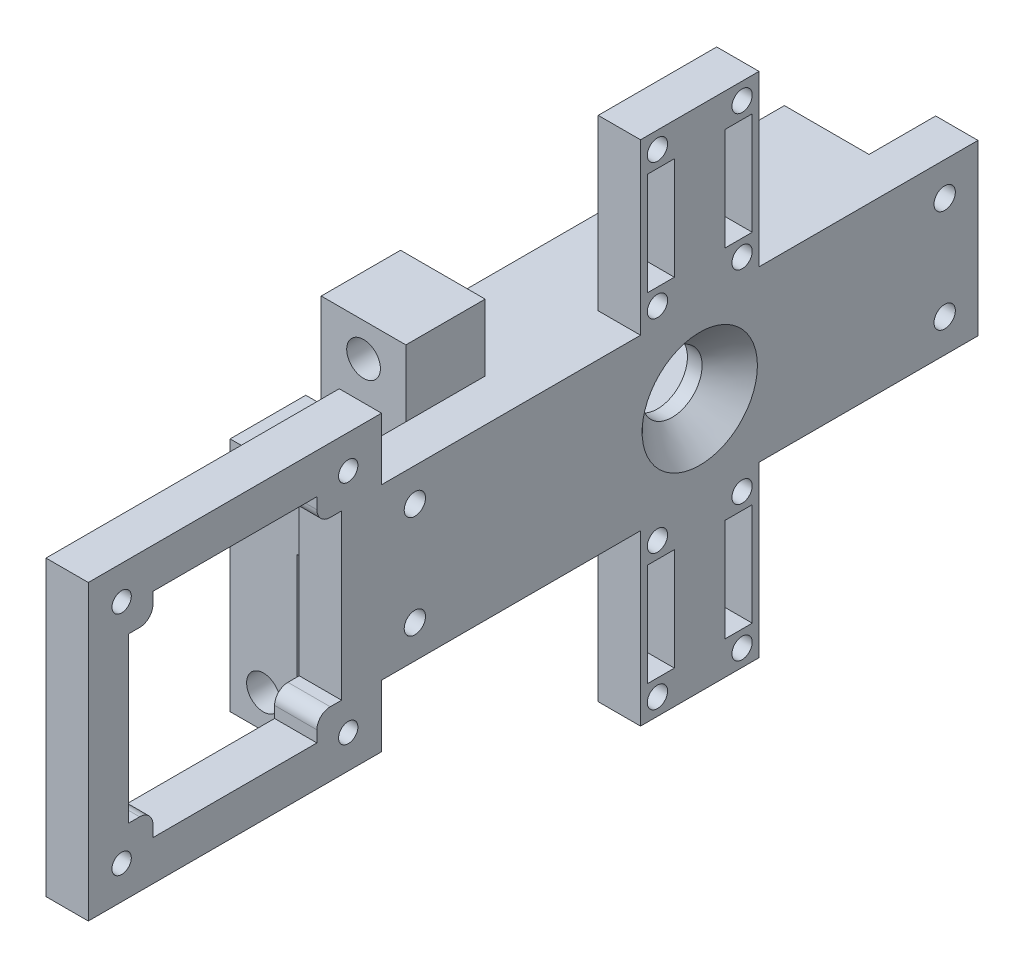
from build123d import *
from build123d.topology import SkipClean

# Parameters (mm, degrees)
SKETCH1_W                                       = 6.35
SKETCH1_H                                       = 89.5
BOSS_EXTRUDE1_DEPTH                             = 25.4
SKETCH4_W                                       = 44
SKETCH4_H                                       = 44
SKETCH4_R                                       = 1.45
BOSS_EXTRUDE2_DEPTH                             = 6.35
CSK_FOR_M8_FLAT_HEAD_MACHINE_SCREW1_D           = 9
CSK_FOR_M8_FLAT_HEAD_MACHINE_SCREW1_DEPTH       = 17.5
CSK_FOR_M8_FLAT_HEAD_MACHINE_SCREW1_CSINK_D     = 17.3
CSK_FOR_M8_FLAT_HEAD_MACHINE_SCREW1_CSINK_ANGLE = 90
CSK_FOR_M8_FLAT_HEAD_MACHINE_SCREW1_TIP         = 2.703872786
SKETCH2_W                                       = 69.5
SKETCH2_H                                       = 25.4
SKETCH2_W_2                                     = 52.8
SKETCH2_H_2                                     = 14.7
BOSS_EXTRUDE3_DEPTH                             = 12.7
SKETCH9_R                                       = 1.6
CUT_EXTRUDE1_DEPTH                              = 6.35
SKETCH10_W                                      = 17.78
SKETCH10_H                                      = 25.4
SKETCH10_R                                      = 1.524
BOSS_EXTRUDE4_DEPTH                             = 6.35
SKETCH11_W                                      = 4.064
SKETCH11_H                                      = 15.4
CUT_EXTRUDE2_DEPTH                              = 6.35
SKETCH14_W                                      = 12.7
SKETCH14_H                                      = 11.9
BOSS_EXTRUDE5_DEPTH                             = 10
SKETCH15_R                                      = 2.5273
CUT_EXTRUDE4_DEPTH                              = 7
SKETCH16_W                                      = 11.35
SKETCH16_H                                      = 10
BOSS_EXTRUDE6_DEPTH                             = 13.671834
SKETCH17_W                                      = 10
SKETCH17_H                                      = 11.35
BOSS_EXTRUDE7_DEPTH                             = 25.452256
SKETCH18_R                                      = 2.5273
CUT_EXTRUDE5_DEPTH                              = 7
SKETCH19_W                                      = 5.3384296
SKETCH19_H                                      = 10
BOSS_EXTRUDE8_DEPTH                             = 5.35
SKETCH21_W                                      = 14.8000118
SKETCH21_H                                      = 5
SKETCH21_W_2                                    = 14.5200118
SKETCH21_H_2                                    = 8
BOSS_EXTRUDE9_DEPTH                             = 8.0000094
SKETCH25_W                                      = 10
SKETCH25_H                                      = 5.35
CUT_EXTRUDE7_DEPTH                              = 5.3384296
CUT_EXTRUDE8_DEPTH                              = 6.35
FILLET1_R                                       = 2
SKETCH27_R                                      = 2.5273
CUT_EXTRUDE10_DEPTH                             = 7
SKETCH29_W                                      = 3
SKETCH29_H                                      = 8.0000094
BOSS_EXTRUDE10_DEPTH                            = 3
SKETCH30_W                                      = 3
SKETCH30_H                                      = 8.00000936
BOSS_EXTRUDE14_DEPTH                            = 5
SKETCH31_W                                      = 3
SKETCH31_H                                      = 8.0000094
BOSS_EXTRUDE15_DEPTH                            = 3.460002
SKETCH32_W                                      = 3
SKETCH32_H                                      = 8.00000914
BOSS_EXTRUDE17_DEPTH                            = 5


with BuildPart() as part:
    # Sketch1 → Boss-Extrude1 (new body)
    with BuildSketch(Plane(origin=(0, 0, 0), x_dir=(1, 0, 0), z_dir=(0, 1, 0))):
        with Locations((3.175, 44.75)):
            Rectangle(SKETCH1_W, SKETCH1_H)
    extrude(amount=BOSS_EXTRUDE1_DEPTH)

    # Sketch4 → Boss-Extrude2 (add)
    with BuildSketch(Plane(origin=(6.35, 0, 0), x_dir=(0, 0, -1), z_dir=(1, 0, 0))):
        with Locations((-22, 12.7)):
            Rectangle(SKETCH4_W, SKETCH4_H)
        with Locations((-39, 29.7)):
            Circle(SKETCH4_R, mode=Mode.SUBTRACT)
        with Locations((-5, 29.7)):
            Circle(SKETCH4_R, mode=Mode.SUBTRACT)
        with Locations((-39, -4.3)):
            Circle(SKETCH4_R, mode=Mode.SUBTRACT)
        with Locations((-5, -4.3)):
            Circle(SKETCH4_R, mode=Mode.SUBTRACT)
    extrude(amount=-BOSS_EXTRUDE2_DEPTH)

    # CSK for M8 Flat Head Machine Screw1
    with Locations(Plane(origin=(6.35, 0, 0), x_dir=(0, 0, -1), z_dir=(1, 0, 0))):
        with Locations((47.75, 12.7)):
            CounterSinkHole(CSK_FOR_M8_FLAT_HEAD_MACHINE_SCREW1_D / 2, CSK_FOR_M8_FLAT_HEAD_MACHINE_SCREW1_CSINK_D / 2, depth=CSK_FOR_M8_FLAT_HEAD_MACHINE_SCREW1_DEPTH, counter_sink_angle=CSK_FOR_M8_FLAT_HEAD_MACHINE_SCREW1_CSINK_ANGLE)
            with Locations((0, 0, -(CSK_FOR_M8_FLAT_HEAD_MACHINE_SCREW1_DEPTH + CSK_FOR_M8_FLAT_HEAD_MACHINE_SCREW1_TIP / 2))):  # 118° drill point
                Cone(0, CSK_FOR_M8_FLAT_HEAD_MACHINE_SCREW1_D / 2, CSK_FOR_M8_FLAT_HEAD_MACHINE_SCREW1_TIP, mode=Mode.SUBTRACT)

    # Sketch2 → Boss-Extrude3 (add)
    with BuildSketch(Plane.ZY):
        with Locations((-44.75, 12.7)):
            Rectangle(SKETCH2_W, SKETCH2_H)
        with Locations((-47.75, 12.7)):
            Rectangle(SKETCH2_W_2, SKETCH2_H_2, mode=Mode.SUBTRACT)
    extrude(amount=BOSS_EXTRUDE3_DEPTH)

    # Sketch9 → Cut-Extrude1 (cut)
    with BuildSketch(Plane.ZY):
        with Locations((-5, 20.4)):
            Circle(SKETCH9_R)
        with Locations((-5, 5)):
            Circle(SKETCH9_R)
        with Locations((-84.5, 5)):
            Circle(SKETCH9_R)
        with Locations((-84.5, 20.4)):
            Circle(SKETCH9_R)
    extrude(amount=-CUT_EXTRUDE1_DEPTH, mode=Mode.SUBTRACT)

    # Sketch10 → Boss-Extrude4 (add)
    with BuildSketch(Plane(origin=(6.35, 0, 0), x_dir=(0, 0, -1), z_dir=(1, 0, 0))):
        with Locations((47.75, 38.1)):
            Rectangle(SKETCH10_W, SKETCH10_H)
        with Locations((41.4, 27.94)):
            Circle(SKETCH10_R, mode=Mode.SUBTRACT)
        with Locations((54.1, 27.94)):
            Circle(SKETCH10_R, mode=Mode.SUBTRACT)
        with Locations((54.1, 48.26)):
            Circle(SKETCH10_R, mode=Mode.SUBTRACT)
        with Locations((41.4, 48.26)):
            Circle(SKETCH10_R, mode=Mode.SUBTRACT)
        with Locations((47.75, -12.7)):
            Rectangle(SKETCH10_W, SKETCH10_H)
        with Locations((41.4, -2.54)):
            Circle(SKETCH10_R, mode=Mode.SUBTRACT)
        with Locations((54.1, -2.54)):
            Circle(SKETCH10_R, mode=Mode.SUBTRACT)
        with Locations((41.4, -22.86)):
            Circle(SKETCH10_R, mode=Mode.SUBTRACT)
        with Locations((54.1, -22.86)):
            Circle(SKETCH10_R, mode=Mode.SUBTRACT)
    extrude(amount=-BOSS_EXTRUDE4_DEPTH)

    # Sketch11 → Cut-Extrude2 (cut)
    with BuildSketch(Plane(origin=(6.35, 0, 0), x_dir=(0, 0, -1), z_dir=(1, 0, 0))):
        with Locations((41.908, -12.7)):
            Rectangle(SKETCH11_W, SKETCH11_H)
        with Locations((53.592, -12.7)):
            Rectangle(SKETCH11_W, SKETCH11_H)
        with Locations((41.908, 38.1)):
            Rectangle(SKETCH11_W, SKETCH11_H)
        with Locations((53.592, 38.1)):
            Rectangle(SKETCH11_W, SKETCH11_H)
    extrude(amount=-CUT_EXTRUDE2_DEPTH, mode=Mode.SUBTRACT)

    # Sketch14 → Boss-Extrude5 (add)
    with BuildSketch(Plane(origin=(0, 25.4, 0), x_dir=(1, 0, 0), z_dir=(0, 1, 0))):
        with Locations((-6.35, 15.95)):
            Rectangle(SKETCH14_W, SKETCH14_H)
    extrude(amount=BOSS_EXTRUDE5_DEPTH)

    # Sketch15 → Cut-Extrude4 (cut)
    with BuildSketch(Plane.XY.offset(-10)):
        with Locations((-6.35, 30.4)):
            Circle(SKETCH15_R)
    extrude(amount=-CUT_EXTRUDE4_DEPTH, mode=Mode.SUBTRACT)

    # Sketch16 → Boss-Extrude6 (add)
    with BuildSketch(Plane.ZY.offset(12.7)):
        with Locations((-15.675, 5)):
            Rectangle(SKETCH16_W, SKETCH16_H)
    extrude(amount=BOSS_EXTRUDE6_DEPTH)

    # Sketch17 → Boss-Extrude7 (add)
    with BuildSketch(Plane.XZ):
        with Locations((-21.371834, -15.675)):
            Rectangle(SKETCH17_W, SKETCH17_H)
    extrude(amount=BOSS_EXTRUDE7_DEPTH)

    # Sketch18 → Cut-Extrude5 (cut)
    with BuildSketch(Plane.XY.offset(-10)):
        with Locations((-21.371834, -20.452256)):
            Circle(SKETCH18_R)
    extrude(amount=-CUT_EXTRUDE5_DEPTH, mode=Mode.SUBTRACT)

    # Sketch19 → Boss-Extrude8 (add)
    with BuildSketch(Plane.XZ):
        with Locations((-15.3692148, -52.925)):
            Rectangle(SKETCH19_W, SKETCH19_H)
    extrude(amount=-BOSS_EXTRUDE8_DEPTH)

    # Sketch21 → Boss-Extrude9 (add)
    with BuildSketch(Plane.XZ):
        with Locations((-17.1000059, -30.200002)):
            Rectangle(SKETCH21_W, SKETCH21_H)
        with Locations((-17.1000059, -76.000002)):
            Rectangle(SKETCH21_W, SKETCH21_H)
        with Locations((-19.9600059, -53.100002)):
            Rectangle(SKETCH21_W_2, SKETCH21_H_2)
    extrude(amount=BOSS_EXTRUDE9_DEPTH)

    # Sketch25 → Cut-Extrude7 (cut)
    with BuildSketch(Plane.ZY.offset(18.0384296)):
        with Locations((-52.925, 2.675)):
            Rectangle(SKETCH25_W, SKETCH25_H)
    extrude(amount=-CUT_EXTRUDE7_DEPTH, mode=Mode.SUBTRACT)


with BuildPart() as cut_extrude7_piece_1:
    # of the separate pieces the step leaves, piece 1, a body of its own (cut_extrude7_pieces)
    add(part.part.solids().sort_by_distance((6.35, 34.7, 0))[0])

    # Sketch26 → Cut-Extrude8 (cut)
    with BuildSketch(Plane(origin=(6.35, 0, 0), x_dir=(0, 0, -1), z_dir=(1, 0, 0))):
        Polygon((-34.3, 28.7), (-9.7, 28.7), (-9.7, 25), (-6, 25), (-6, 0.4), (-9.7, 0.4), (-9.7, -3.3), (-34.3, -3.3), (-34.3, 0.4), (-38, 0.4), (-38, 25), (-34.3, 25), align=None)
    extrude(amount=-CUT_EXTRUDE8_DEPTH, mode=Mode.SUBTRACT)

    # Fillet1
    fillet1_edges = [cut_extrude7_piece_1.edges().sort_by_distance(p)[0] for p in [
        (3.175, 25, 9.7),
        (3.175, 0.4, 9.7),
        (3.175, 0.4, 34.3),
        (3.175, 25, 34.3),
    ]]
    fillet(fillet1_edges, radius=FILLET1_R)


with BuildPart() as cut_extrude7_piece_2:
    # of the separate pieces the step leaves, piece 2, a body of its own (cut_extrude7_pieces)
    add(part.part.solids().sort_by_distance((-12.7, -8.0000094, -49.100002))[0])

    # Sketch27 → Cut-Extrude10 (cut)
    with BuildSketch(Plane.XZ.offset(8.0000094)):
        with Locations(Location((-22.2199964, -53.100002, 0), (0, 0, 270))):
            Circle(SKETCH27_R)
    extrude(amount=-CUT_EXTRUDE10_DEPTH, mode=Mode.SUBTRACT)

    # Sketch29 → Boss-Extrude10 (add)
    with BuildSketch(Plane.XY.offset(-49.100002)):
        with Locations((-14.2, -4.0000047)):
            Rectangle(SKETCH29_W, SKETCH29_H)
    extrude(amount=BOSS_EXTRUDE10_DEPTH)

    # Sketch30 → Boss-Extrude14 (add)
    with BuildSketch(Plane(origin=(-12.7, 0, 0), x_dir=(0, 0, -1), z_dir=(1, 0, 0))):
        with Locations((47.600002, -4.00000472)):
            Rectangle(SKETCH30_W, SKETCH30_H)
    extrude(amount=BOSS_EXTRUDE14_DEPTH)

    # Sketch31 → Boss-Extrude15 (add)
    with BuildSketch(Plane(origin=(0, 0, -57.100002), x_dir=(-1, 0, 0), z_dir=(0, 0, -1))):
        with Locations((14.2, -4.0000047)):
            Rectangle(SKETCH31_W, SKETCH31_H)
    extrude(amount=BOSS_EXTRUDE15_DEPTH)

    # Sketch32 → Boss-Extrude17 (add)
    with SkipClean():  # the faces are left unmerged after this step: merging them gives an invalid solid
        with BuildSketch(Plane(origin=(-12.7, 0, 0), x_dir=(0, 0, -1), z_dir=(1, 0, 0))):
            with Locations((59.060004, -4.00000483)):
                Rectangle(SKETCH32_W, SKETCH32_H)
        extrude(amount=BOSS_EXTRUDE17_DEPTH)


solid = Compound([cut_extrude7_piece_1.part, cut_extrude7_piece_2.part])
